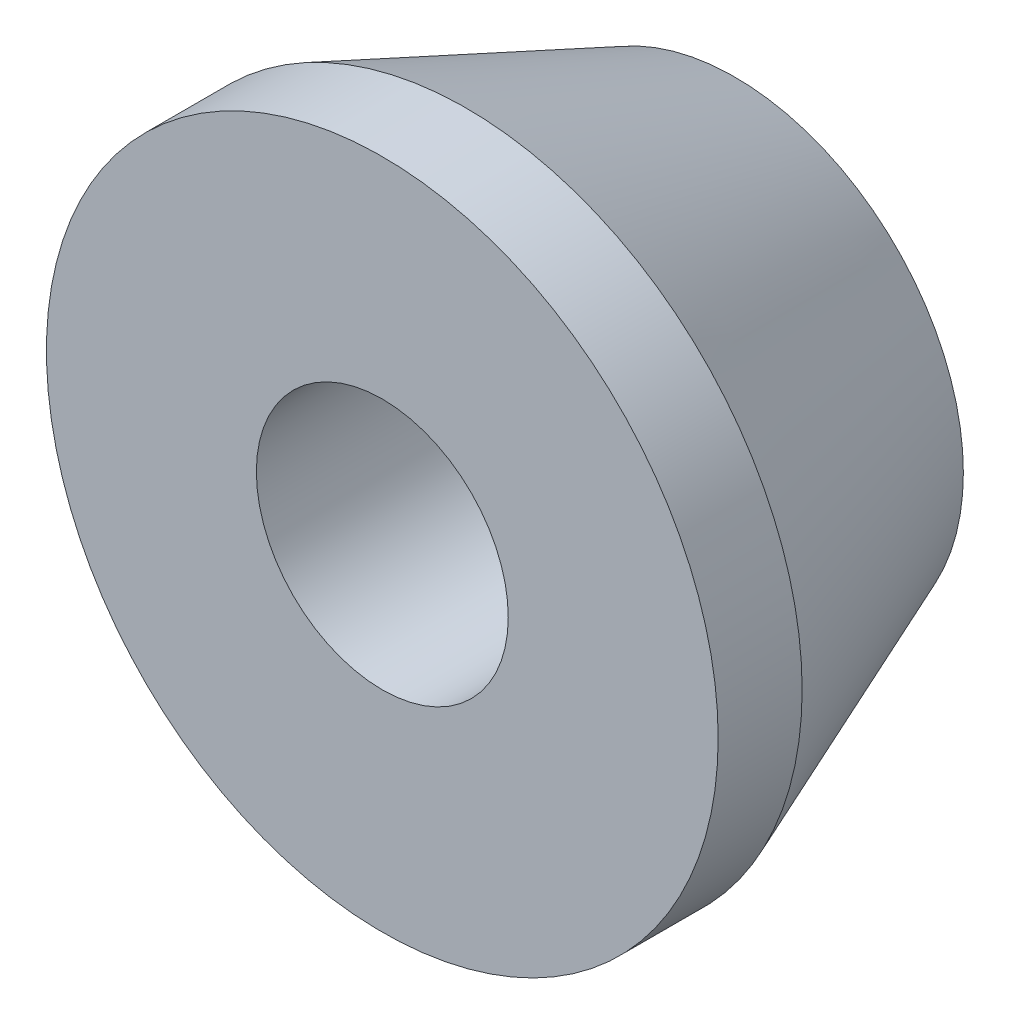
from build123d import *


with BuildPart() as part:
    # Sketch1 → Revolve1 (revolve)
    with BuildSketch(Plane(origin=(0, 0, 0), x_dir=(1, 0, 0), z_dir=(0, 1, 0))):
        Polygon((12.7, 0), (4.7625, 0), (4.7625, 13.335), (8.636, 13.335), (12.7, 3.175), align=None)
    revolve(axis=Axis((0, 0, 0), (0, 0, -1)))


solid = part.part
